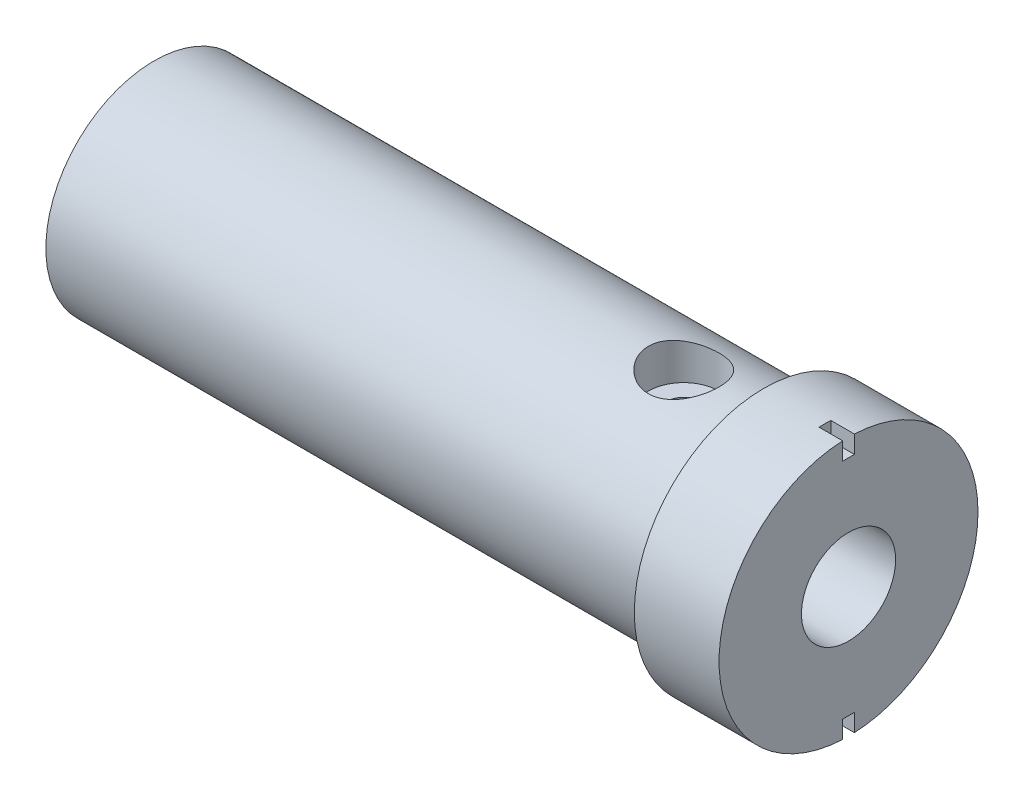
from build123d import *

# Parameters (mm, degrees)
CUT_EXTRUDE1_DEPTH = 21
CUT_EXTRUDE2_DEPTH = 2
SKETCH3_R          = 1.475
CUT_EXTRUDE3_DEPTH = 62.650709647
CUT_EXTRUDE4_START = -2.8
SKETCH3_4_R        = 3
SKETCH3_4_R_2      = 1.475
CUT_EXTRUDE4_DEPTH = 59.850709743
CUT_EXTRUDE5_START = -2
CUT_EXTRUDE5_DEPTH = 2


with BuildPart() as part:
    # Sketch1 → Revolve1 (revolve)
    with BuildSketch(Plane(origin=(0, 0, 0), x_dir=(1, 0, 0), z_dir=(0, 1, 0))):
        Polygon((0, 0), (0, 11), (-7.2, 11), (-7.2, 9.2), (-59, 9.2), (-59, 0), align=None)
    revolve(axis=Axis((0, 0, 0), (-1, 0, 0)))

    # Sketch2 → Cut-Extrude1 (cut)
    with BuildSketch(Plane(origin=(0, 0, 0), x_dir=(0, 0, -1), z_dir=(1, 0, 0))):
        with BuildLine():
            Line((2.527844932, 3.1), (-2.527844932, 3.1))
            ThreePointArc((-2.527844932, 3.1), (-1.715899221, -3.613265817), (4, 0))
            ThreePointArc((4, 0), (3.613265817, 1.715899221), (2.527844932, 3.1))
        make_face()
    extrude(amount=-CUT_EXTRUDE1_DEPTH, mode=Mode.SUBTRACT)

    # Sketch2_4 → Cut-Extrude2 (cut)
    with BuildSketch(Plane(origin=(0, 0, 0), x_dir=(0, 0, -1), z_dir=(1, 0, 0))):
        with BuildLine():
            ThreePointArc((2.527844932, 3.1), (0, 4), (-2.527844932, 3.1))
            Line((-2.527844932, 3.1), (2.527844932, 3.1))
        make_face()
    extrude(amount=-CUT_EXTRUDE2_DEPTH, mode=Mode.SUBTRACT)

    # Sketch3 → Cut-Extrude3 (cut, through all)
    with BuildSketch(Plane.XZ.offset(-3.1)):
        with Locations((-14, 0)):
            Circle(SKETCH3_R)
    extrude(amount=-CUT_EXTRUDE3_DEPTH, mode=Mode.SUBTRACT)

    # Sketch3_4 → Cut-Extrude4 (cut, through all)
    with BuildSketch(Plane.XZ.offset(-3.1).offset(CUT_EXTRUDE4_START)):
        with Locations((-14, 0)):
            Circle(SKETCH3_4_R)
        with Locations((-14, 0)):
            Circle(SKETCH3_4_R_2, mode=Mode.SUBTRACT)
    extrude(amount=-CUT_EXTRUDE4_DEPTH, mode=Mode.SUBTRACT)

    # Sketch2_6 → Cut-Extrude5 (cut)
    with BuildSketch(Plane(origin=(0, 0, 0), x_dir=(0, 0, -1), z_dir=(1, 0, 0)).offset(CUT_EXTRUDE5_START)):
        with BuildLine():
            Line((0.5, 9.488630488), (0.5, 10.988630488))
            ThreePointArc((0.5, 10.988630488), (0, 11), (-0.5, 10.988630488))
            Line((-0.5, 10.988630488), (-0.5, 9.488630488))
            Line((-0.5, 9.488630488), (0.5, 9.488630488))
        make_face()
        with BuildLine():
            ThreePointArc((-0.5, -10.988630488), (0, -11), (0.5, -10.988630488))
            Line((0.5, -10.988630488), (0.5, -9.488630488))
            Line((0.5, -9.488630488), (-0.5, -9.488630488))
            Line((-0.5, -9.488630488), (-0.5, -10.988630488))
        make_face()
    extrude(amount=CUT_EXTRUDE5_DEPTH, mode=Mode.SUBTRACT)


solid = part.part
